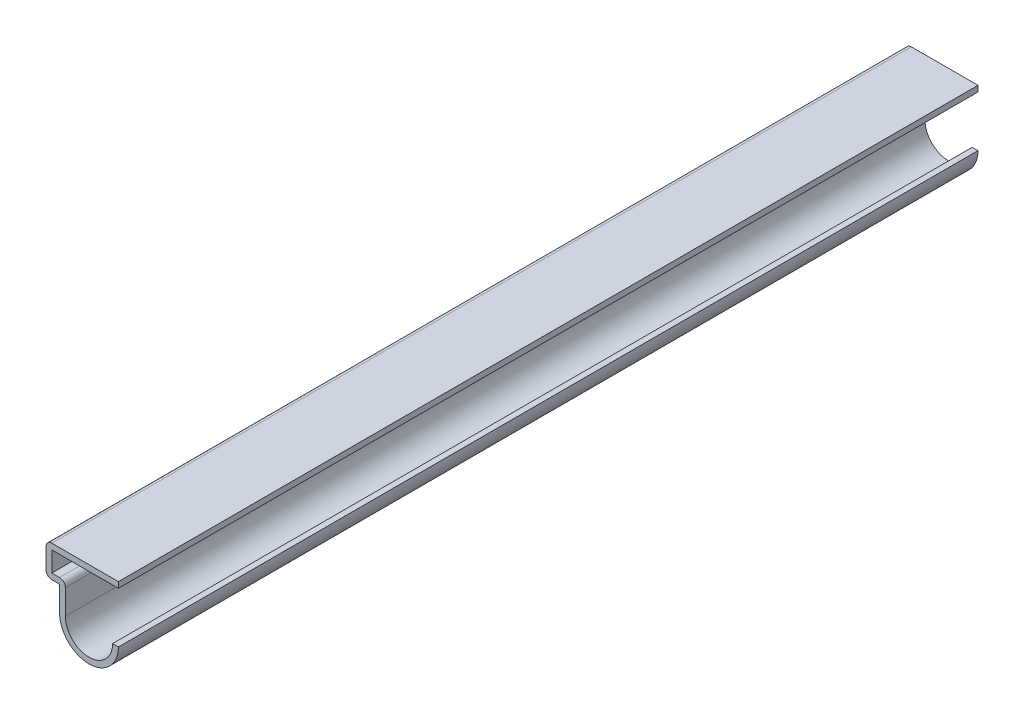
from build123d import *

# Parameters (mm, degrees)
EXTRUDE_THIN1_DEPTH = 150.8125
FILLET1_R           = 1.016


with BuildPart() as part:
    # Sketch1 → Extrude-Thin1 (new body)
    with BuildSketch(Plane.XY):
        with BuildLine():
            ThreePointArc((0, 0), (-5.159375, -5.159375), (-10.31875, 0))
            Line((-10.31875, 0), (-10.31875, 4.365625))
            Line((-10.31875, 4.365625), (-12.7, 4.365625))
            Line((-12.7, 4.365625), (-12.7, 9.921875))
            Line((-12.7, 9.921875), (0, 9.921875))
            Line((0, 9.921875), (0, 8.905875))
            Line((0, 8.905875), (-11.684, 8.905875))
            Line((-11.684, 8.905875), (-11.684, 5.381625))
            Line((-11.684, 5.381625), (-9.30275, 5.381625))
            Line((-9.30275, 5.381625), (-9.30275, 0))
            ThreePointArc((-9.30275, 0), (-5.159375, -4.143375), (-1.016, 0))
            Line((-1.016, 0), (0, 0))
        make_face()
    extrude(amount=-EXTRUDE_THIN1_DEPTH)

    # Fillet1
    fillet1_edges = [part.edges().sort_by_distance(p)[0] for p in [
        (-9.30275, 5.381625, -75.40625),
        (-12.7, 4.365625, -75.40625),
        (-12.7, 9.921875, -75.40625),
    ]]
    fillet(fillet1_edges, radius=FILLET1_R)


solid = part.part
